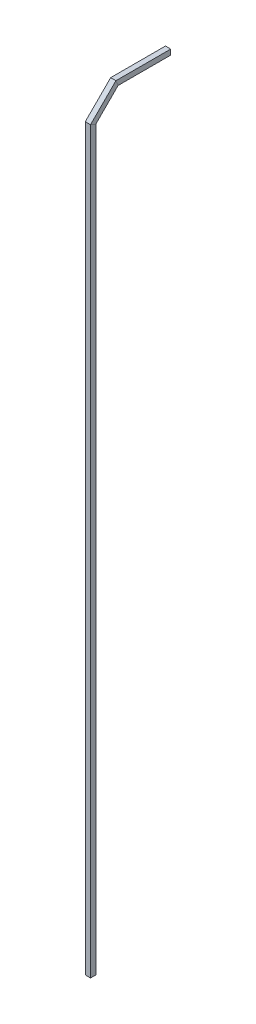
from build123d import *

# Parameters (mm, degrees)
SKETCH_1_W = 10
SKETCH_1_H = 10


with BuildPart() as part:
    # 扫描2: sweep along a path in 草图3
    with BuildLine(Plane(origin=(0, 0, 0), x_dir=(0, 0, -1), z_dir=(1, 0, 0))) as sweep_2_path:
        Line((5, 0), (5, 1400))
        Line((5, 1400), (47.426406871, 1442.426406871))
        Line((47.426406871, 1442.426406871), (147.426406871, 1442.426406871))
    # 草图1 → 扫描2 (sweep)
    with BuildSketch(Plane(origin=(0, 0, 0), x_dir=(1, 0, 0), z_dir=(0, 1, 0))):
        Rectangle(SKETCH_1_W, SKETCH_1_H)
    sweep(path=sweep_2_path.line, transition=Transition.RIGHT)


solid = part.part
